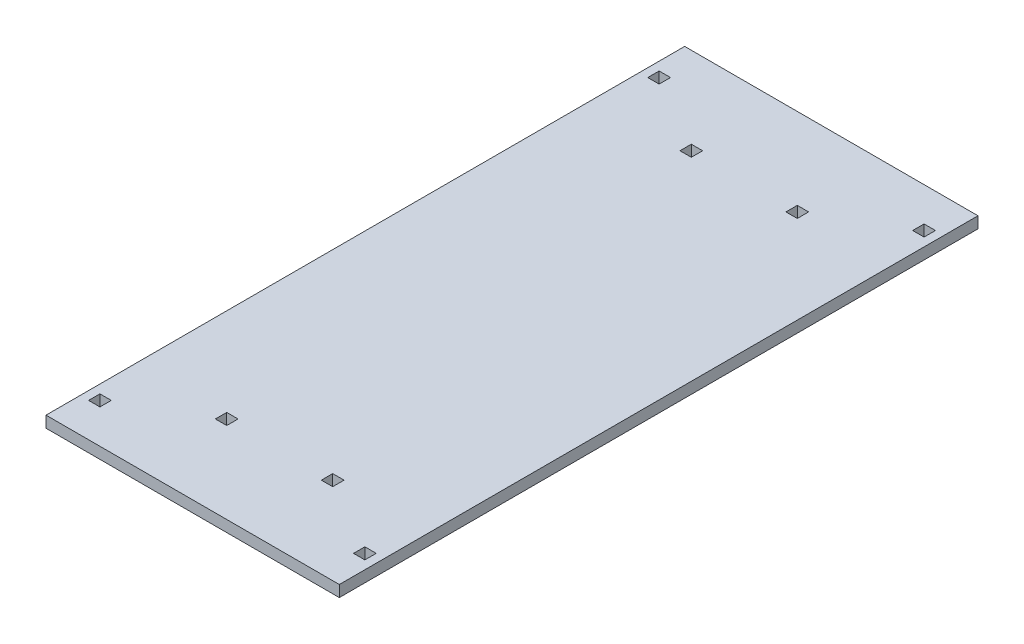
from build123d import *

# Parameters (mm, degrees)
SKETCH1_W           = 310
SKETCH1_H           = 675
SKETCH1_W_2         = 300
SKETCH1_H_2         = 665
SKETCH1_W_3         = 260
SKETCH1_H_3         = 625
BOSS_EXTRUDE1_DEPTH = 12
SKETCH2_W           = 12
SKETCH2_H           = 12
CUT_EXTRUDE1_DEPTH  = 13
SKETCH3_W           = 12
SKETCH3_H           = 12
CUT_EXTRUDE2_DEPTH  = 13


with BuildPart() as part:
    # Sketch1 → Boss-Extrude1 (new body)
    with BuildSketch(Plane(origin=(0, 0, 0), x_dir=(1, 0, 0), z_dir=(0, 1, 0))):
        Rectangle(SKETCH1_W, SKETCH1_H)
        Rectangle(SKETCH1_W_2, SKETCH1_H_2, mode=Mode.SUBTRACT)
        Rectangle(SKETCH1_W_2, SKETCH1_H_2)
        Rectangle(SKETCH1_W_3, SKETCH1_H_3, mode=Mode.SUBTRACT)
        Rectangle(SKETCH1_W_3, SKETCH1_H_3)
    extrude(amount=BOSS_EXTRUDE1_DEPTH)

    # Sketch2 → Cut-Extrude1 (cut, through all)
    with BuildSketch(Plane(origin=(0, 12, 0), x_dir=(1, 0, 0), z_dir=(0, 1, 0))):
        with Locations((-140, -295.5)):
            Rectangle(SKETCH2_W, SKETCH2_H)
        with Locations((-140, 295.5)):
            Rectangle(SKETCH2_W, SKETCH2_H)
        with Locations((140, 295.5)):
            Rectangle(SKETCH2_W, SKETCH2_H)
        with Locations((140, -295.5)):
            Rectangle(SKETCH2_W, SKETCH2_H)
    extrude(amount=-CUT_EXTRUDE1_DEPTH, mode=Mode.SUBTRACT)

    # Sketch3 → Cut-Extrude2 (cut, through all)
    with BuildSketch(Plane(origin=(0, 12, 0), x_dir=(1, 0, 0), z_dir=(0, 1, 0))):
        with Locations((-56, -245.5)):
            Rectangle(SKETCH3_W, SKETCH3_H)
        with Locations((56, -245.5)):
            Rectangle(SKETCH3_W, SKETCH3_H)
    cut_extrude2 = extrude(amount=-CUT_EXTRUDE2_DEPTH, mode=Mode.SUBTRACT)

    # Mirror1: Cut-Extrude2 across plane
    add(cut_extrude2.mirror(Plane.XY), mode=Mode.SUBTRACT)


solid = part.part
